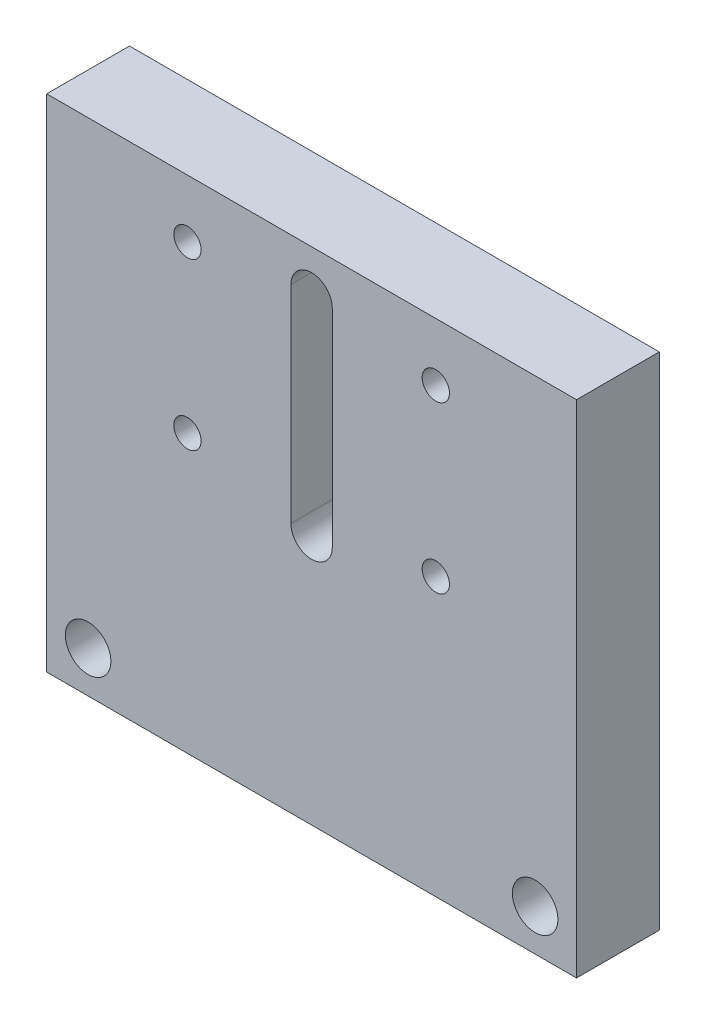
from build123d import *

# Parameters (mm, degrees)
BOSS_EXTRUDE1_DEPTH  = 64
SKETCH4_R            = 2.25
CUT_EXTRUDE2_DEPTH   = 10
LPATTERN2_COUNT      = 2
LPATTERN2_PITCH      = 12
LPATTERN2_COUNT_DIR2 = 2
LPATTERN2_PITCH_DIR2 = 56.5
CUT_EXTRUDE3_DEPTH   = 10
SKETCH6_R            = 2.75
CUT_EXTRUDE4_DEPTH   = 1.5
LPATTERN3_COUNT      = 2
LPATTERN3_PITCH      = 12
LPATTERN3_COUNT_DIR2 = 2
LPATTERN3_PITCH_DIR2 = 22.2
SKETCH7_W            = 93.831963321
SKETCH7_H            = 64.757190555
CUT_EXTRUDE5_DEPTH   = 65
SKETCH8_R            = 2.75
CUT_EXTRUDE6_DEPTH   = 11
M4_TAPPED_HOLE1_D    = 3.3


with BuildPart() as part:
    # Sketch1 → Boss-Extrude1 (new body)
    with BuildSketch(Plane(origin=(0, 0, 0), x_dir=(0, 0, -1), z_dir=(1, 0, 0))):
        Polygon((0, 60.5), (0, 0), (98, 0), (98, 10), (10, 10), (10, 60.5), align=None)
    extrude(amount=BOSS_EXTRUDE1_DEPTH)

    # Sketch4 → Cut-Extrude2 (cut)
    with BuildSketch(Plane(origin=(0, 10, 0), x_dir=(1, 0, 0), z_dir=(0, 1, 0))):
        with Locations(Location((60.25, 89, 0), (0, 0, 270))):  # turned: the seam where the file's is
            Circle(SKETCH4_R)
    cut_extrude2 = extrude(amount=-CUT_EXTRUDE2_DEPTH, mode=Mode.SUBTRACT)

    # LPattern2: Cut-Extrude2 2 × 2
    with Locations(*[(-j * LPATTERN2_PITCH_DIR2, 0, i * LPATTERN2_PITCH) for i in range(LPATTERN2_COUNT) for j in range(LPATTERN2_COUNT_DIR2) if (i, j) != (0, 0)]):
        add(cut_extrude2, mode=Mode.SUBTRACT)

    # Sketch5 → Cut-Extrude3 (cut)
    with BuildSketch(Plane(origin=(0, 0, -10), x_dir=(-1, 0, 0), z_dir=(0, 0, -1))):
        with BuildLine():
            Line((-29.5, 55.3), (-29.5, 30.3))
            ThreePointArc((-29.5, 30.3), (-32, 27.8), (-34.5, 30.3))
            Line((-34.5, 30.3), (-34.5, 55.3))
            ThreePointArc((-34.5, 55.3), (-32, 57.8), (-29.5, 55.3))
        make_face()
    extrude(amount=-CUT_EXTRUDE3_DEPTH, mode=Mode.SUBTRACT)

    # Sketch6 → Cut-Extrude4 (cut)
    with BuildSketch(Plane(origin=(0, 10, 0), x_dir=(1, 0, 0), z_dir=(0, 1, 0))):
        with Locations(Location((38, 94.1, 0), (0, 0, 270))):  # turned: the seam where the file's is
            Circle(SKETCH6_R)
    cut_extrude4 = extrude(amount=-CUT_EXTRUDE4_DEPTH, mode=Mode.SUBTRACT)

    # LPattern3: Cut-Extrude4 2 × 2
    with Locations(*[(-i * LPATTERN3_PITCH, 0, j * LPATTERN3_PITCH_DIR2) for i in range(LPATTERN3_COUNT) for j in range(LPATTERN3_COUNT_DIR2) if (i, j) != (0, 0)]):
        add(cut_extrude4, mode=Mode.SUBTRACT)

    # Sketch7 → Cut-Extrude5 (cut, through all)
    with BuildSketch(Plane(origin=(64, 0, 0), x_dir=(0, 0, -1), z_dir=(1, 0, 0))):
        with Locations((56.915981661, 28.121404723)):
            Rectangle(SKETCH7_W, SKETCH7_H)
    extrude(amount=-CUT_EXTRUDE5_DEPTH, mode=Mode.SUBTRACT)

    # Sketch8 → Cut-Extrude6 (cut, through all)
    with BuildSketch(Plane.XY):
        with Locations((59, 5)):
            Circle(SKETCH8_R)
    cut_extrude6 = extrude(amount=-CUT_EXTRUDE6_DEPTH, mode=Mode.SUBTRACT)

    # Mirror1: Cut-Extrude6 across plane
    add(cut_extrude6.mirror(Plane.ZY.offset(-32)), mode=Mode.SUBTRACT)

    # M4 Tapped Hole1 (through all)
    with Locations(Plane(origin=(0, 0, -10), x_dir=(-1, 0, 0), z_dir=(0, 0, -1))):
        with Locations((-17, 53.5), (-47, 33.5), (-17, 33.5), (-47, 53.5)):
            Hole(M4_TAPPED_HOLE1_D / 2)


solid = part.part
